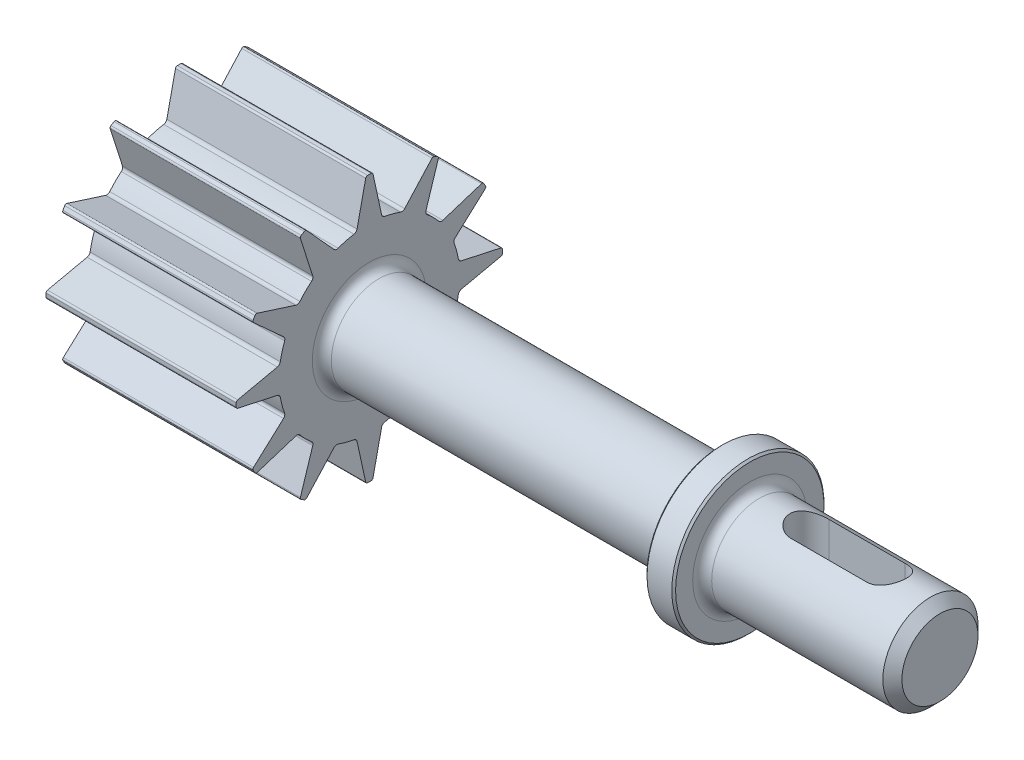
from build123d import *

# Parameters (mm, degrees)
BOSS_EXTRUDE1_DEPTH = 10
CIRPATTERN1_COUNT   = 12
SKETCH2_R           = 2.5
BOSS_EXTRUDE2_DEPTH = 30
SKETCH6_W           = 1.5
SKETCH6_H           = 1.5
CUT_EXTRUDE1_DEPTH  = 4
CHAMFER2_SIZE       = 0.5
FILLET1_R           = 0.5
CHAMFER3_SIZE       = 0.1
FILLET2_R           = 0.5
SKETCH9_R           = 3.25
CUT_EXTRUDE2_DEPTH  = 1


with BuildPart() as part:
    # Sketch1 → Boss-Extrude1 (new body)
    with BuildSketch(Plane(origin=(0, 0, 0), x_dir=(0, 0, -1), z_dir=(1, 0, 0))):
        with BuildLine():
            Line((-0.645900046, 4.835422864), (-0.191806417, 6.920636512))
            ThreePointArc((-0.191806417, 6.920636512), (-0.157364247, 6.976799854), (-0.095460151, 6.999349067))
            ThreePointArc((-0.095460151, 6.999349067), (0, 7), (0.095460151, 6.999349067))
            ThreePointArc((0.095460151, 6.999349067), (0.157364247, 6.976799854), (0.191806417, 6.920636512))
            Line((0.191806417, 6.920636512), (0.645900046, 4.835422864))
            ThreePointArc((0.645900046, 4.835422864), (0.703017017, 4.733506728), (0.807327282, 4.680889089))
            ThreePointArc((0.807327282, 4.680889089), (0, -4.75), (-0.807327282, 4.680889089))
            ThreePointArc((-0.807327282, 4.680889089), (-0.703017017, 4.733506728), (-0.645900046, 4.835422864))
        make_face()
    boss_extrude1 = extrude(amount=BOSS_EXTRUDE1_DEPTH)

    # CirPattern1: Boss-Extrude1 ×12 about axis
    cirpattern1_axis = Axis((0, 0, 0), (1, 0, 0))
    for i in range(1, CIRPATTERN1_COUNT):
        add(boss_extrude1.rotate(cirpattern1_axis, i * 360 / CIRPATTERN1_COUNT))

    # Sketch2 → Boss-Extrude2 (add)
    with BuildSketch(Plane(origin=(10, 0, 0), x_dir=(0, 0, -1), z_dir=(1, 0, 0))):
        Circle(SKETCH2_R)
    extrude(amount=BOSS_EXTRUDE2_DEPTH)

    # Sketch6 → Revolve1 (revolve)
    with BuildSketch(Plane(origin=(0, 0, 0), x_dir=(1, 0, 0), z_dir=(0, 1, 0))):
        with Locations((29.25, 3.25)):
            Rectangle(SKETCH6_W, SKETCH6_H)
    revolve(axis=Axis((0, 0, 0), (1, 0, 0)))

    # Sketch8 → Cut-Extrude1 (cut)
    with BuildSketch(Plane(origin=(0, 2.5, 0), x_dir=(1, 0, 0), z_dir=(0, 1, 0))):
        with BuildLine():
            Line((37, -0.844273094), (33, -0.844273094))
            ThreePointArc((33, -0.844273094), (32, 0.155726906), (33, 1.155726906))
            Line((33, 1.155726906), (37, 1.155726906))
            ThreePointArc((37, 1.155726906), (38, 0.155726906), (37, -0.844273094))
        make_face()
    extrude(amount=-CUT_EXTRUDE1_DEPTH, mode=Mode.SUBTRACT)

    # Chamfer2
    chamfer2_edges = [part.edges().sort_by_distance(p)[0] for p in [
        (40, 0, 2.5),
    ]]
    chamfer(chamfer2_edges, length=CHAMFER2_SIZE)

    # Fillet1
    fillet1_edges = [part.edges().sort_by_distance(p)[0] for p in [
        (28.5, 0, 2.5),
        (30, 0, 2.5),
    ]]
    fillet(fillet1_edges, radius=FILLET1_R)

    # Chamfer3
    chamfer3_edges = [part.edges().sort_by_distance(p)[0] for p in [
        (30, 0, 4),
        (28.5, 0, 4),
    ]]
    chamfer(chamfer3_edges, length=CHAMFER3_SIZE)

    # Fillet2
    fillet2_edges = [part.edges().sort_by_distance(p)[0] for p in [
        (10, 0, 2.5),
    ]]
    fillet(fillet2_edges, radius=FILLET2_R)

    # Sketch9 → Cut-Extrude2 (cut)
    with BuildSketch(Plane.ZY):
        Circle(SKETCH9_R)
    extrude(amount=-CUT_EXTRUDE2_DEPTH, mode=Mode.SUBTRACT)


solid = part.part
